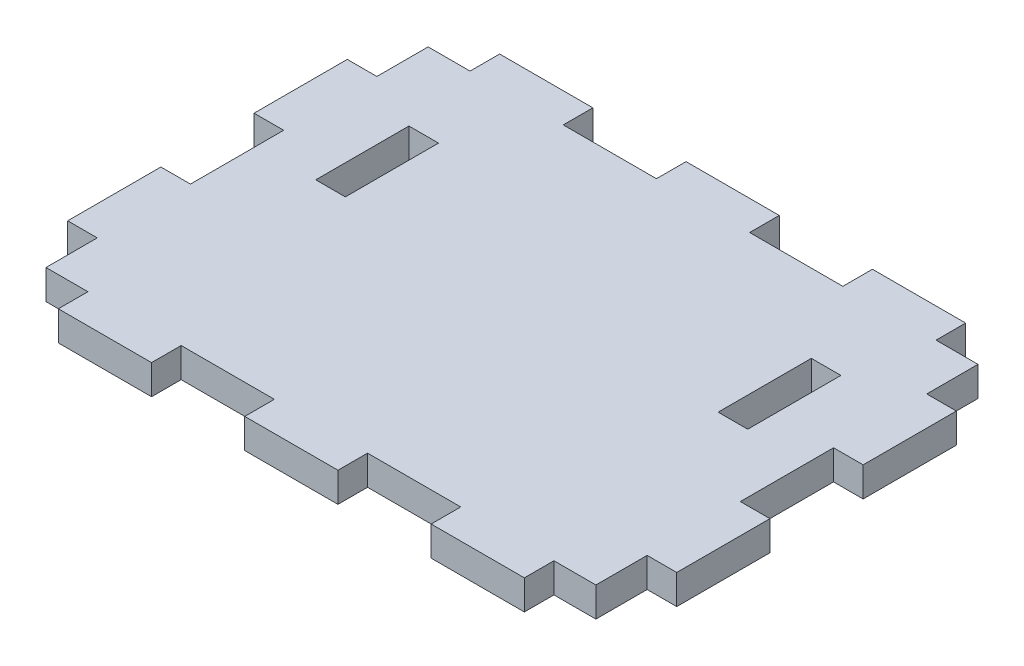
from build123d import *

# Parameters (mm, degrees)
SKETCH1_W           = 65.35
SKETCH1_H           = 47.35
BOSS_EXTRUDE1_DEPTH = 3.175
SKETCH2_W           = 4.5
SKETCH2_H           = 3.175
SKETCH2_W_2         = 3.175
SKETCH2_H_2         = 10
SKETCH2_W_3         = 10
CUT_EXTRUDE1_DEPTH  = 4.175
SKETCH3_W           = 3.175
SKETCH3_H           = 10
CUT_EXTRUDE2_DEPTH  = 4.175


with BuildPart() as part:
    # Sketch1 → Boss-Extrude1 (new body)
    with BuildSketch(Plane(origin=(0, 0, 0), x_dir=(1, 0, 0), z_dir=(0, 1, 0))):
        with Locations((32.675, 23.675)):
            Rectangle(SKETCH1_W, SKETCH1_H)
    extrude(amount=BOSS_EXTRUDE1_DEPTH)

    # Sketch2 → Cut-Extrude1 (cut, through all)
    with BuildSketch(Plane.XZ):
        with Locations((59.925, -45.7625)):
            Rectangle(SKETCH2_W, SKETCH2_H)
        Polygon((65.35, -38.675), (62.175, -38.675), (62.175, -44.175), (62.175, -47.35), (65.35, -47.35), align=None)
        with Locations((63.7625, -23.675)):
            Rectangle(SKETCH2_W_2, SKETCH2_H_2)
        Polygon((62.175, -8.675), (65.35, -8.675), (65.35, 0), (62.175, 0), (62.175, -3.175), align=None)
        with Locations((59.925, -1.5875)):
            Rectangle(SKETCH2_W, SKETCH2_H)
        with Locations((42.675, -1.5875)):
            Rectangle(SKETCH2_W_3, SKETCH2_H)
        with Locations((42.675, -45.7625)):
            Rectangle(SKETCH2_W_3, SKETCH2_H)
        with Locations((22.675, -45.7625)):
            Rectangle(SKETCH2_W_3, SKETCH2_H)
        with Locations((5.425, -45.7625)):
            Rectangle(SKETCH2_W, SKETCH2_H)
        Polygon((0, -47.35), (3.175, -47.35), (3.175, -44.175), (3.175, -38.675), (0, -38.675), align=None)
        with Locations((1.5875, -23.675)):
            Rectangle(SKETCH2_W_2, SKETCH2_H_2)
        Polygon((3.175, -3.175), (3.175, 0), (0, 0), (0, -8.675), (3.175, -8.675), align=None)
        with Locations((5.425, -1.5875)):
            Rectangle(SKETCH2_W, SKETCH2_H)
        with Locations((22.675, -1.5875)):
            Rectangle(SKETCH2_W_3, SKETCH2_H)
    extrude(amount=-CUT_EXTRUDE1_DEPTH, mode=Mode.SUBTRACT)

    # Sketch3 → Cut-Extrude2 (cut, through all)
    with BuildSketch(Plane.XZ):
        with Locations((54.2625, -30.791497658)):
            Rectangle(SKETCH3_W, SKETCH3_H)
        with Locations((11.0875, -30.791497658)):
            Rectangle(SKETCH3_W, SKETCH3_H)
    extrude(amount=-CUT_EXTRUDE2_DEPTH, mode=Mode.SUBTRACT)


solid = part.part
